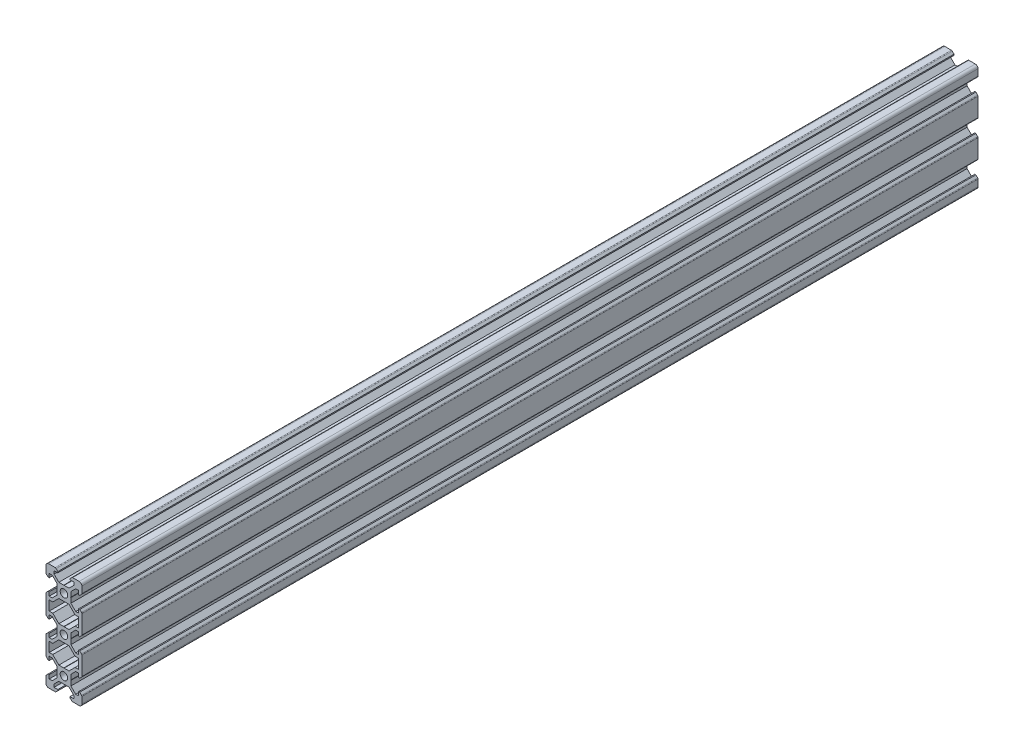
from build123d import *

# Parameters (mm, degrees)
SKETCH1_R           = 2.1
BOSS_EXTRUDE2_DEPTH = 500


with BuildPart() as part:
    # Sketch1 → Boss-Extrude2 (new body)
    with BuildSketch(Plane.XY):
        with BuildLine():
            Line((-8.5, 10), (-4.862792737, 10))
            ThreePointArc((-4.862792737, 10), (-4.598292737, 9.947387679), (-4.374060464, 9.797560464))
            Line((-4.374060464, 9.797560464), (-3.3865, 8.81))
            Line((-3.3865, 8.81), (-3.3865, 8.2))
            Line((-3.3865, 8.2), (-5.5, 8.2))
            Line((-5.5, 8.2), (-5.5, 6.561))
            Line((-5.5, 6.561), (-2.8395, 3.9005))
            Line((-2.8395, 3.9005), (-0.1, 3.9005))
            Line((-0.1, 3.9005), (0, 3.8005))
            Line((0, 3.8005), (0.1, 3.9005))
            Line((0.1, 3.9005), (2.8395, 3.9005))
            Line((2.8395, 3.9005), (5.5, 6.561))
            Line((5.5, 6.561), (5.5, 8.2))
            Line((5.5, 8.2), (3.3865, 8.2))
            Line((3.3865, 8.2), (3.3865, 8.81))
            Line((3.3865, 8.81), (4.374060464, 9.797560464))
            ThreePointArc((4.374060464, 9.797560464), (4.598292737, 9.947387679), (4.862792737, 10))
            Line((4.862792737, 10), (8.5, 10))
            ThreePointArc((8.5, 10), (9.560660172, 9.560660172), (10, 8.5))
            Line((10, 8.5), (10, 4.862792737))
            ThreePointArc((10, 4.862792737), (9.947387679, 4.598292737), (9.797560464, 4.374060464))
            Line((9.797560464, 4.374060464), (8.81, 3.3865))
            Line((8.81, 3.3865), (8.2, 3.3865))
            Line((8.2, 3.3865), (8.2, 5.5))
            Line((8.2, 5.5), (6.561, 5.5))
            Line((6.561, 5.5), (3.9005, 2.8395))
            Line((3.9005, 2.8395), (3.9005, 0.1))
            Line((3.9005, 0.1), (3.8005, 0))
            Line((3.8005, 0), (3.9005, -0.1))
            Line((3.9005, -0.1), (3.9005, -2.8395))
            Line((3.9005, -2.8395), (6.561, -5.5))
            Line((6.561, -5.5), (8.2, -5.5))
            Line((8.2, -5.5), (8.2, -3.3865))
            Line((8.2, -3.3865), (8.81, -3.3865))
            Line((8.81, -3.3865), (9.797560464, -4.374060464))
            ThreePointArc((9.797560464, -4.374060464), (9.947387679, -4.598292737), (10, -4.862792737))
            Line((10, -4.862792737), (10, -15.137207263))
            ThreePointArc((10, -15.137207263), (9.947387679, -15.401707263), (9.797560464, -15.625939536))
            Line((9.797560464, -15.625939536), (8.81, -16.6135))
            Line((8.81, -16.6135), (8.2, -16.6135))
            Line((8.2, -16.6135), (8.2, -14.5))
            Line((8.2, -14.5), (6.561, -14.5))
            Line((6.561, -14.5), (3.9005, -17.1605))
            Line((3.9005, -17.1605), (3.9005, -19.9))
            Line((3.9005, -19.9), (3.8005, -20))
            Line((3.8005, -20), (3.9005, -20.1))
            Line((3.9005, -20.1), (3.9005, -22.8395))
            Line((3.9005, -22.8395), (6.561, -25.5))
            Line((6.561, -25.5), (8.2, -25.5))
            Line((8.2, -25.5), (8.2, -23.3865))
            Line((8.2, -23.3865), (8.81, -23.3865))
            Line((8.81, -23.3865), (9.797560464, -24.374060464))
            ThreePointArc((9.797560464, -24.374060464), (9.947387679, -24.598292737), (10, -24.862792737))
            Line((10, -24.862792737), (10, -35.137207263))
            ThreePointArc((10, -35.137207263), (9.947387679, -35.401707263), (9.797560464, -35.625939536))
            Line((9.797560464, -35.625939536), (8.81, -36.6135))
            Line((8.81, -36.6135), (8.2, -36.6135))
            Line((8.2, -36.6135), (8.2, -34.5))
            Line((8.2, -34.5), (6.561, -34.5))
            Line((6.561, -34.5), (3.9005, -37.1605))
            Line((3.9005, -37.1605), (3.9005, -39.9))
            Line((3.9005, -39.9), (3.8005, -40))
            Line((3.8005, -40), (3.9005, -40.1))
            Line((3.9005, -40.1), (3.9005, -42.8395))
            Line((3.9005, -42.8395), (6.561, -45.5))
            Line((6.561, -45.5), (8.2, -45.5))
            Line((8.2, -45.5), (8.2, -43.3865))
            Line((8.2, -43.3865), (8.81, -43.3865))
            Line((8.81, -43.3865), (9.797560464, -44.374060464))
            ThreePointArc((9.797560464, -44.374060464), (9.947387679, -44.598292737), (10, -44.862792737))
            Line((10, -44.862792737), (10, -48.5))
            ThreePointArc((10, -48.5), (9.560660172, -49.560660172), (8.5, -50))
            Line((8.5, -50), (4.862792737, -50))
            ThreePointArc((4.862792737, -50), (4.598292737, -49.947387679), (4.374060464, -49.797560464))
            Line((4.374060464, -49.797560464), (3.3865, -48.81))
            Line((3.3865, -48.81), (3.3865, -48.2))
            Line((3.3865, -48.2), (5.5, -48.2))
            Line((5.5, -48.2), (5.5, -46.561))
            Line((5.5, -46.561), (2.8395, -43.9005))
            Line((2.8395, -43.9005), (0.1, -43.9005))
            Line((0.1, -43.9005), (0, -43.8005))
            Line((0, -43.8005), (-0.1, -43.9005))
            Line((-0.1, -43.9005), (-2.8395, -43.9005))
            Line((-2.8395, -43.9005), (-5.5, -46.561))
            Line((-5.5, -46.561), (-5.5, -48.2))
            Line((-5.5, -48.2), (-3.3865, -48.2))
            Line((-3.3865, -48.2), (-3.3865, -48.81))
            Line((-3.3865, -48.81), (-4.374060464, -49.797560464))
            ThreePointArc((-4.374060464, -49.797560464), (-4.598292737, -49.947387679), (-4.862792737, -50))
            Line((-4.862792737, -50), (-8.5, -50))
            ThreePointArc((-8.5, -50), (-9.560660172, -49.560660172), (-10, -48.5))
            Line((-10, -48.5), (-10, -44.862792737))
            ThreePointArc((-10, -44.862792737), (-9.947387679, -44.598292737), (-9.797560464, -44.374060464))
            Line((-9.797560464, -44.374060464), (-8.81, -43.3865))
            Line((-8.81, -43.3865), (-8.2, -43.3865))
            Line((-8.2, -43.3865), (-8.2, -45.5))
            Line((-8.2, -45.5), (-6.561, -45.5))
            Line((-6.561, -45.5), (-3.9005, -42.8395))
            Line((-3.9005, -42.8395), (-3.9005, -40.1))
            Line((-3.9005, -40.1), (-3.8005, -40))
            Line((-3.8005, -40), (-3.9005, -39.9))
            Line((-3.9005, -39.9), (-3.9005, -37.1605))
            Line((-3.9005, -37.1605), (-6.561, -34.5))
            Line((-6.561, -34.5), (-8.2, -34.5))
            Line((-8.2, -34.5), (-8.2, -36.6135))
            Line((-8.2, -36.6135), (-8.81, -36.6135))
            Line((-8.81, -36.6135), (-9.797560464, -35.625939536))
            ThreePointArc((-9.797560464, -35.625939536), (-9.947387679, -35.401707263), (-10, -35.137207263))
            Line((-10, -35.137207263), (-10, -24.862792737))
            ThreePointArc((-10, -24.862792737), (-9.947387679, -24.598292737), (-9.797560464, -24.374060464))
            Line((-9.797560464, -24.374060464), (-8.81, -23.3865))
            Line((-8.81, -23.3865), (-8.2, -23.3865))
            Line((-8.2, -23.3865), (-8.2, -25.5))
            Line((-8.2, -25.5), (-6.561, -25.5))
            Line((-6.561, -25.5), (-3.9005, -22.8395))
            Line((-3.9005, -22.8395), (-3.9005, -20.1))
            Line((-3.9005, -20.1), (-3.8005, -20))
            Line((-3.8005, -20), (-3.9005, -19.9))
            Line((-3.9005, -19.9), (-3.9005, -17.1605))
            Line((-3.9005, -17.1605), (-6.561, -14.5))
            Line((-6.561, -14.5), (-8.2, -14.5))
            Line((-8.2, -14.5), (-8.2, -16.6135))
            Line((-8.2, -16.6135), (-8.81, -16.6135))
            Line((-8.81, -16.6135), (-9.797560464, -15.625939536))
            ThreePointArc((-9.797560464, -15.625939536), (-9.947387679, -15.401707263), (-10, -15.137207263))
            Line((-10, -15.137207263), (-10, -4.862792737))
            ThreePointArc((-10, -4.862792737), (-9.947387679, -4.598292737), (-9.797560464, -4.374060464))
            Line((-9.797560464, -4.374060464), (-8.81, -3.3865))
            Line((-8.81, -3.3865), (-8.2, -3.3865))
            Line((-8.2, -3.3865), (-8.2, -5.5))
            Line((-8.2, -5.5), (-6.561, -5.5))
            Line((-6.561, -5.5), (-3.9005, -2.8395))
            Line((-3.9005, -2.8395), (-3.9005, -0.1))
            Line((-3.9005, -0.1), (-3.8005, 0))
            Line((-3.8005, 0), (-3.9005, 0.1))
            Line((-3.9005, 0.1), (-3.9005, 2.8395))
            Line((-3.9005, 2.8395), (-6.561, 5.5))
            Line((-6.561, 5.5), (-8.2, 5.5))
            Line((-8.2, 5.5), (-8.2, 3.3865))
            Line((-8.2, 3.3865), (-8.81, 3.3865))
            Line((-8.81, 3.3865), (-9.797560464, 4.374060464))
            ThreePointArc((-9.797560464, 4.374060464), (-9.947387679, 4.598292737), (-10, 4.862792737))
            Line((-10, 4.862792737), (-10, 8.5))
            ThreePointArc((-10, 8.5), (-9.560660172, 9.560660172), (-8.5, 10))
        make_face()
        Circle(SKETCH1_R, mode=Mode.SUBTRACT)
        with Locations((0, -20)):
            Circle(SKETCH1_R, mode=Mode.SUBTRACT)
        with Locations((0, -40)):
            Circle(SKETCH1_R, mode=Mode.SUBTRACT)
        Polygon((-8.2, -12.7), (-8.2, -7.3), (-6.239, -7.3), (-5.5, -6.561), (-2.8395, -3.9005), (-0.1, -3.9005), (0, -3.8005), (0.1, -3.9005), (2.8395, -3.9005), (5.5, -6.561), (6.239, -7.3), (8.2, -7.3), (8.2, -12.7), (6.239, -12.7), (5.5, -13.439), (2.8395, -16.0995), (0.1, -16.0995), (0, -16.1995), (-0.1, -16.0995), (-2.8395, -16.0995), (-5.5, -13.439), (-6.239, -12.7), align=None, mode=Mode.SUBTRACT)
        Polygon((2.8395, -23.9005), (5.5, -26.561), (6.239, -27.3), (8.2, -27.3), (8.2, -32.7), (6.239, -32.7), (5.5, -33.439), (2.8395, -36.0995), (0.1, -36.0995), (0, -36.1995), (-0.1, -36.0995), (-2.8395, -36.0995), (-5.5, -33.439), (-6.239, -32.7), (-8.2, -32.7), (-8.2, -27.3), (-6.239, -27.3), (-5.5, -26.561), (-2.8395, -23.9005), (-0.1, -23.9005), (0, -23.8005), (0.1, -23.9005), align=None, mode=Mode.SUBTRACT)
    extrude(amount=BOSS_EXTRUDE2_DEPTH)


solid = part.part
